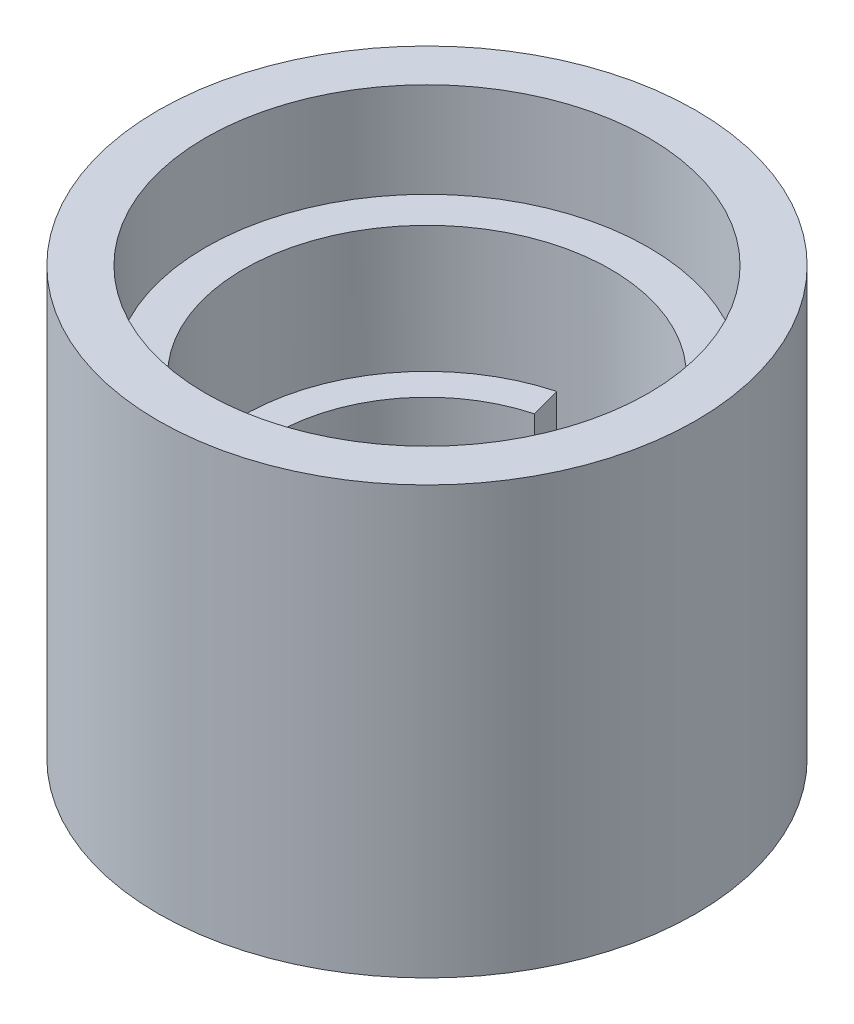
from build123d import *

# Parameters (mm, degrees)
SKETCH1_R           = 10.795
SKETCH1_R_2         = 6.096
BOSS_EXTRUDE1_DEPTH = 17.145
SKETCH2_R           = 8.89
CUT_EXTRUDE1_DEPTH  = 3.81
SKETCH3_R           = 7.366
SKETCH3_R_2         = 6.096
CUT_EXTRUDE2_DEPTH  = 5.08
CUT_EXTRUDE3_DEPTH  = 8.255


with BuildPart() as part:
    # Sketch1 → Boss-Extrude1 (new body)
    with BuildSketch(Plane(origin=(0, 0, 0), x_dir=(1, 0, 0), z_dir=(0, 1, 0))):
        Circle(SKETCH1_R)
        Circle(SKETCH1_R_2, mode=Mode.SUBTRACT)
    extrude(amount=BOSS_EXTRUDE1_DEPTH)

    # Sketch2 → Cut-Extrude1 (cut)
    with BuildSketch(Plane(origin=(0, 17.145, 0), x_dir=(1, 0, 0), z_dir=(0, 1, 0))):
        Circle(SKETCH2_R)
    extrude(amount=-CUT_EXTRUDE1_DEPTH, mode=Mode.SUBTRACT)

    # Sketch3 → Cut-Extrude2 (cut)
    with BuildSketch(Plane(origin=(0, 13.335, 0), x_dir=(1, 0, 0), z_dir=(0, 1, 0))):
        Circle(SKETCH3_R)
        Circle(SKETCH3_R_2, mode=Mode.SUBTRACT)
    extrude(amount=-CUT_EXTRUDE2_DEPTH, mode=Mode.SUBTRACT)

    # Sketch4 → Cut-Extrude3 (cut)
    with BuildSketch(Plane(origin=(0, 8.255, 0), x_dir=(1, 0, 0), z_dir=(0, 1, 0))):
        with BuildLine():
            Line((0, 0), (-1.906461086, 7.115009636))
            ThreePointArc((-1.906461086, 7.115009636), (0, 7.366), (1.906461086, 7.115009636))
            Line((1.906461086, 7.115009636), (0, 0))
        make_face()
    extrude(amount=-CUT_EXTRUDE3_DEPTH, mode=Mode.SUBTRACT)


solid = part.part
